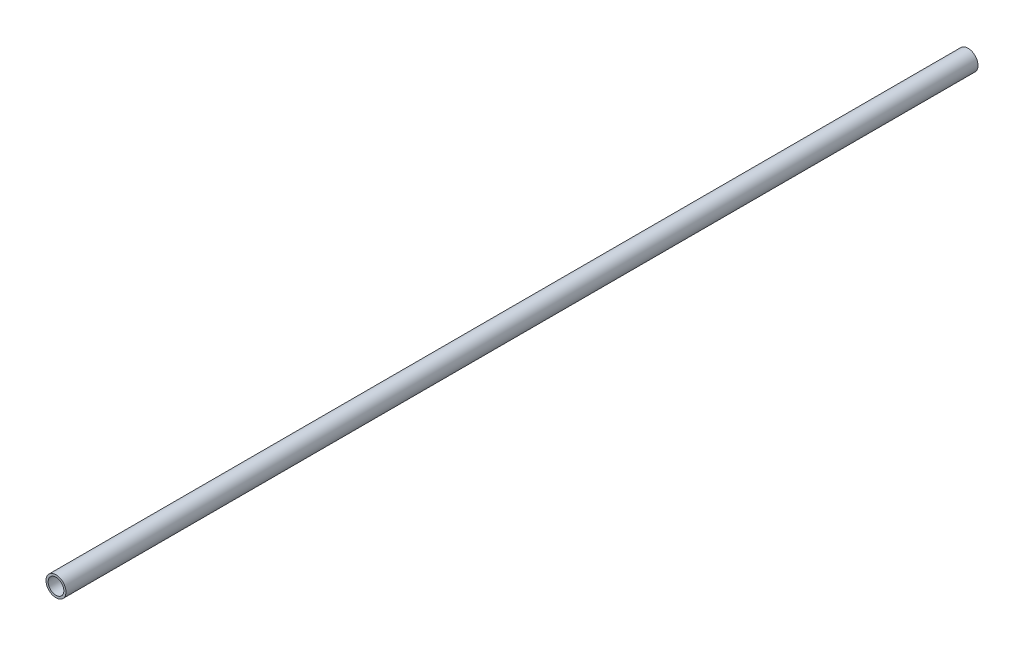
from build123d import *

# Parameters (mm, degrees)
SKETCH3_R                = 13.335
SKETCH3_R_2              = 10.4648
BOSS_EXTRUDE1_DEPTH      = 762
BOSS_EXTRUDE1_DEPTH_BACK = 762
SKETCH4_R                = 13.335
SKETCH4_R_2              = 10.4648
CUT_EXTRUDE2_DEPTH       = 307.356669


with BuildPart() as part:
    # Sketch3 → Boss-Extrude1 (new body, two sides)
    with BuildSketch(Plane.XY) as boss_extrude1_sk:
        Circle(SKETCH3_R)
        Circle(SKETCH3_R_2, mode=Mode.SUBTRACT)
    extrude(amount=BOSS_EXTRUDE1_DEPTH)
    extrude(boss_extrude1_sk.sketch, amount=-BOSS_EXTRUDE1_DEPTH_BACK)

    # Sketch4 → Cut-Extrude2 (cut)
    with BuildSketch(Plane.XY.offset(762)):
        Circle(SKETCH4_R)
        Circle(SKETCH4_R_2, mode=Mode.SUBTRACT)
    extrude(amount=-CUT_EXTRUDE2_DEPTH, mode=Mode.SUBTRACT)


solid = part.part
